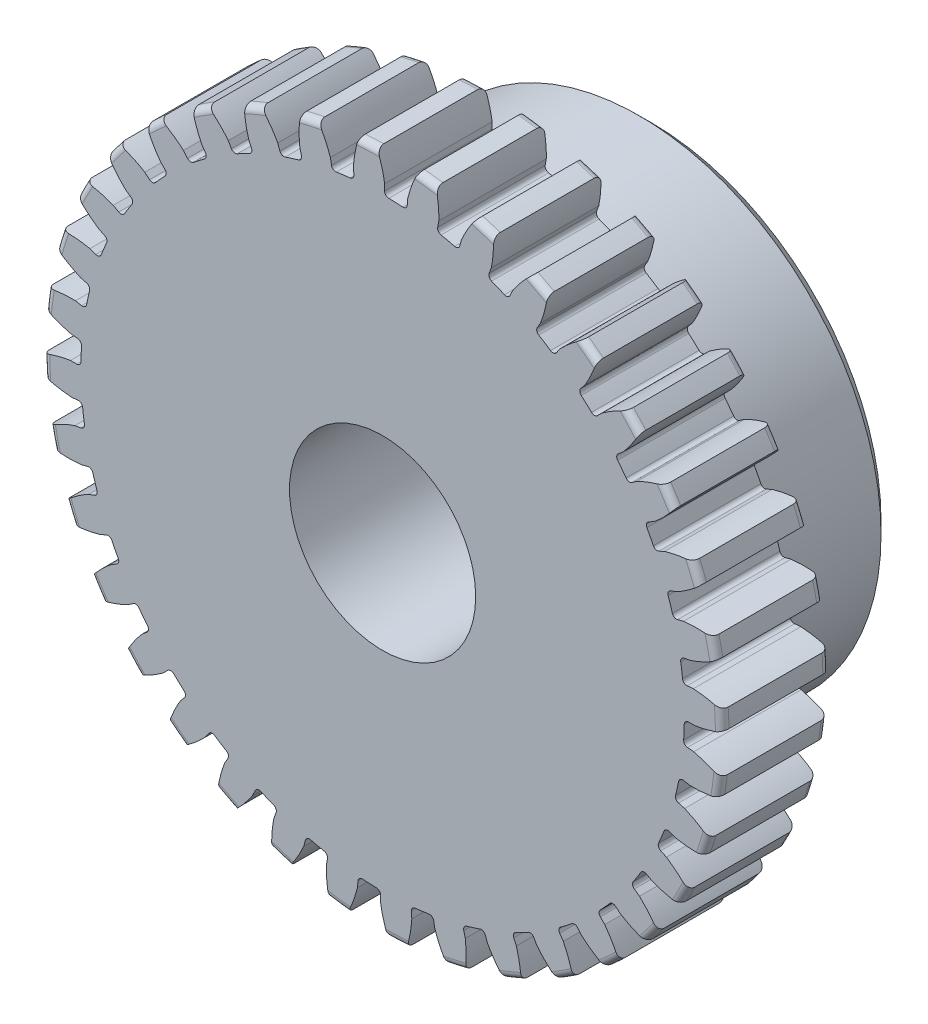
from build123d import *

# Parameters (mm, degrees)
SKETCH1_R                = 20.066
BOSS_EXTRUDE1_DEPTH      = 6.35
SKETCH2_W                = 9.525
SKETCH2_H                = 14.2875
REVOLVE1_ANGLE           = 360
FILLET2_R                = 0.40132
CUT_EXTRUDE1_DEPTH       = 16.875
FILLET1_R                = 0.2493645
CIRPATTERN1_COUNT        = 36
FILLET1_OF_CIRPATTERN1_R = 0.2493645
SKETCH5_R                = 4.7625
CUT_EXTRUDE2_DEPTH       = 16.875
CHAMFER1_SIZE            = 0.714375
SKETCH6_R                = 5.5
CUT_EXTRUDE3_DEPTH       = 16.875


with BuildPart() as part:
    # Sketch1 → Boss-Extrude1 (new body)
    with BuildSketch(Plane.XY):
        Circle(SKETCH1_R)
    extrude(amount=-BOSS_EXTRUDE1_DEPTH)

    # Sketch2 → Revolve1 (revolve, symmetric)
    with BuildSketch(Plane(origin=(0, 0, 0), x_dir=(0, 0, -1), z_dir=(1, 0, 0))) as revolve1_sk:
        with Locations((11.1125, 7.14375)):
            Rectangle(SKETCH2_W, SKETCH2_H)
    revolve(axis=Axis((0, 0, -6.35), (0, 0, -1)), revolution_arc=REVOLVE1_ANGLE / 2)
    revolve(revolve1_sk.sketch, axis=Axis((0, 0, -6.35), (0, 0, 1)), revolution_arc=REVOLVE1_ANGLE / 2)

    # Fillet2
    fillet2_edges = [part.edges().sort_by_distance(p)[0] for p in [
        (-20.066, 0, 0),
        (-20.066, 0, -6.35),
        (0, -14.2875, -6.35),
    ]]
    fillet(fillet2_edges, radius=FILLET2_R)

    # Sketch4 → Cut-Extrude1 (cut, through all)
    with BuildSketch(Plane.XY):
        with BuildLine():
            Line((0.119863022, 18.442823048), (0.119863022, 17.825105335))
            ThreePointArc((0.119863022, 17.825105335), (0.77753957, 17.80854232), (1.434157013, 17.767721886))
            Line((1.434157013, 17.767721886), (1.487994785, 18.383088986))
            add(Edge.make_bspline(
                [(3.588260473, 21.933290983), (1.978189723, 20.400079012), (1.487994785, 18.383088986)],
                knots=[0, 0, 0, 1, 1, 1], degree=2))
            ThreePointArc((3.588260473, 21.933290983), (0.969437499, 22.2037172), (-1.662989269, 22.162566035))
            add(Edge.make_bspline(
                [(-1.662989269, 22.162566035), (-0.192673894, 20.494861186), (0.119863022, 18.442823048)],
                knots=[0, 0, 0, 1, 1, 1], degree=2))
        make_face()
    cut_extrude1 = extrude(amount=-CUT_EXTRUDE1_DEPTH, mode=Mode.SUBTRACT)

    # Fillet1
    fillet1_edges = [part.edges().sort_by_distance(p)[0] for p in [
        (1.434157013, 17.767721886, -3.175),
        (0.119863022, 17.825105335, -3.175),
    ]]
    fillet(fillet1_edges, radius=FILLET1_R)

    # CirPattern1: Cut-Extrude1 ×36 about axis
    cirpattern1_axis = Axis((0, 0, -6.35), (0, 0, 1))
    for i in range(1, CIRPATTERN1_COUNT):
        add(cut_extrude1.rotate(cirpattern1_axis, i * 360 / CIRPATTERN1_COUNT), mode=Mode.SUBTRACT)

    # Fillet1 of CirPattern1
    fillet1_of_cirpattern1_edges = [part.edges().sort_by_distance(p)[0] for p in [
        (-1.672963581, 17.746829018, -3.175),
        (-2.977255024, 17.575115927, -3.175),
        (-4.729252023, 17.186707731, -3.175),
        (-5.983910684, 16.791115516, -3.175),
        (-7.641844536, 16.104377027, -3.175),
        (-8.808748245, 15.496925556, -3.175),
        (-10.32224347, 14.532722976, -3.175),
        (-11.365936448, 13.731869355, -3.175),
        (-12.689006259, 12.519499491, -3.175),
        (-13.577776424, 11.549577253, -3.175),
        (-14.670220014, 10.125877349, -3.175),
        (-15.377062534, 9.01635709, -3.175),
        (-16.205686557, 7.424585548, -3.175),
        (-16.70912438, 6.209179479, -3.175),
        (-17.248751514, 4.497701473, -3.175),
        (-17.533487937, 3.213339092, -3.175),
        (-17.767721886, 1.434157013, -3.175),
        (-17.825105335, 0.119863022, -3.175),
        (-17.746829018, -1.672963581, -3.175),
        (-17.575115927, -2.977255024, -3.175),
        (-17.186707731, -4.729252023, -3.175),
        (-16.791115516, -5.983910684, -3.175),
        (-16.104377027, -7.641844536, -3.175),
        (-15.496925556, -8.808748245, -3.175),
        (-14.532722976, -10.32224347, -3.175),
        (-13.731869355, -11.365936448, -3.175),
        (-12.519499491, -12.689006259, -3.175),
        (-11.549577253, -13.577776424, -3.175),
        (-10.125877349, -14.670220014, -3.175),
        (-9.01635709, -15.377062534, -3.175),
        (-7.424585548, -16.205686557, -3.175),
        (-6.209179479, -16.70912438, -3.175),
        (-4.497701473, -17.248751514, -3.175),
        (-3.213339092, -17.533487937, -3.175),
        (-1.434157013, -17.767721886, -3.175),
        (-0.119863022, -17.825105335, -3.175),
        (1.672963581, -17.746829018, -3.175),
        (2.977255024, -17.575115927, -3.175),
        (4.729252023, -17.186707731, -3.175),
        (5.983910684, -16.791115516, -3.175),
        (7.641844536, -16.104377027, -3.175),
        (8.808748245, -15.496925556, -3.175),
        (10.32224347, -14.532722976, -3.175),
        (11.365936448, -13.731869355, -3.175),
        (12.689006259, -12.519499491, -3.175),
        (13.577776424, -11.549577253, -3.175),
        (14.670220014, -10.125877349, -3.175),
        (15.377062534, -9.01635709, -3.175),
        (16.205686557, -7.424585548, -3.175),
        (16.70912438, -6.209179479, -3.175),
        (17.248751514, -4.497701473, -3.175),
        (17.533487937, -3.213339092, -3.175),
        (17.767721886, -1.434157013, -3.175),
        (17.825105335, -0.119863022, -3.175),
        (17.746829018, 1.672963581, -3.175),
        (17.575115927, 2.977255024, -3.175),
        (17.186707731, 4.729252023, -3.175),
        (16.791115516, 5.983910684, -3.175),
        (16.104377027, 7.641844536, -3.175),
        (15.496925556, 8.808748245, -3.175),
        (14.532722976, 10.32224347, -3.175),
        (13.731869355, 11.365936448, -3.175),
        (12.519499491, 12.689006259, -3.175),
        (11.549577253, 13.577776424, -3.175),
        (10.125877349, 14.670220014, -3.175),
        (9.01635709, 15.377062534, -3.175),
        (7.424585548, 16.205686557, -3.175),
        (6.209179479, 16.70912438, -3.175),
        (4.497701473, 17.248751514, -3.175),
        (3.213339092, 17.533487937, -3.175),
    ]]
    fillet(fillet1_of_cirpattern1_edges, radius=FILLET1_OF_CIRPATTERN1_R)

    # Sketch5 → Cut-Extrude2 (cut, through all)
    with BuildSketch(Plane.XY):
        Circle(SKETCH5_R)
    extrude(amount=-CUT_EXTRUDE2_DEPTH, mode=Mode.SUBTRACT)

    # Chamfer1
    chamfer1_edges = [part.edges().sort_by_distance(p)[0] for p in [
        (-4.7625, 0, -15.875),
        (-4.7625, 0, 0),
        (0, -14.2875, -15.875),
    ]]
    chamfer(chamfer1_edges, length=CHAMFER1_SIZE)

    # Sketch6 → Cut-Extrude3 (cut, through all)
    with BuildSketch(Plane.XY):
        Circle(SKETCH6_R)
    extrude(amount=-CUT_EXTRUDE3_DEPTH, mode=Mode.SUBTRACT)


solid = part.part
